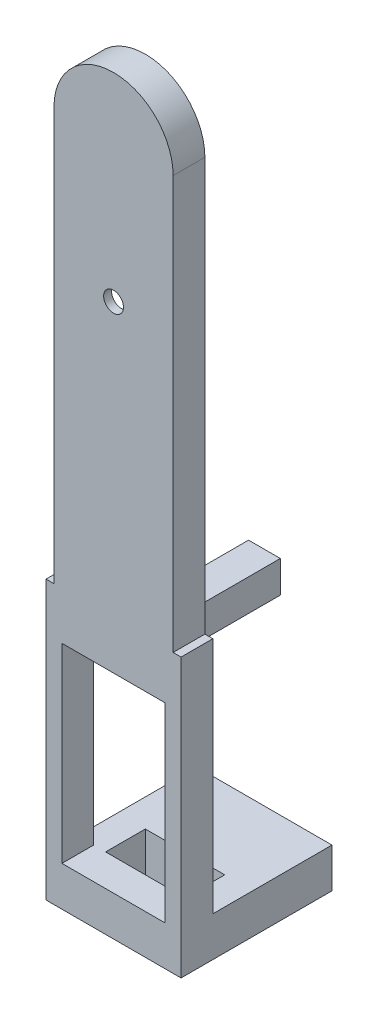
from build123d import *

# Parameters (mm, degrees)
EXTRUDE_1_DEPTH     = 4
CUT_EXTRUDE_1_DEPTH = 3
SKETCH_5_R          = 1.25
CUT_EXTRUDE_2_DEPTH = 12.4
SKETCH_6_W          = 17
SKETCH_6_H          = 35
EXTRUDE_2_DEPTH     = 4
SKETCH_7_W          = 13
SKETCH_7_H          = 24
CUT_EXTRUDE_3_DEPTH = 12.1
SKETCH_8_W          = 4
SKETCH_8_H          = 4
SKETCH_8_R          = 1.15
EXTRUDE_3_DEPTH     = 15
EXTRUDE_4_DEPTH     = 5
SKETCH_10_R         = 1.15
CUT_EXTRUDE_4_DEPTH = 12.7


with BuildPart() as part:
    # 草圖1 → 填料-伸長1 (new body)
    with BuildSketch(Plane.XY):
        with BuildLine():
            Line((7.5, 0), (7.5, 52))
            ThreePointArc((7.5, 52), (0, 59.5), (-7.5, 52))
            Line((-7.5, 52), (-7.5, 0))
            Line((-7.5, 0), (7.5, 0))
        make_face()
    extrude(amount=EXTRUDE_1_DEPTH)

    # 草圖3 → 除料-伸長1 (cut)
    with BuildSketch(Plane.XY):
        with BuildLine():
            ThreePointArc((-2.132795501, 52), (0, 54.132795501), (2.132795501, 52))
            Line((2.132795501, 52), (5, 34.5))
            Line((5, 34.5), (2.114741289, 16.658021353))
            ThreePointArc((2.114741289, 16.658021353), (-0.171540182, 14.864665347), (-2.142213835, 17))
            Line((-2.142213835, 17), (-5, 34.5))
            Line((-5, 34.5), (-2.132795501, 52))
        make_face()
    extrude(amount=CUT_EXTRUDE_1_DEPTH, mode=Mode.SUBTRACT)

    # 草圖5 → 除料-伸長2 (cut)
    with BuildSketch(Plane.XY):
        with Locations((0, 34.5)):
            Circle(SKETCH_5_R)
    extrude(amount=CUT_EXTRUDE_2_DEPTH, mode=Mode.SUBTRACT)

    # 草圖6 → 填料-伸長2 (add)
    with BuildSketch(Plane.XY):
        with Locations((0, -17.5)):
            Rectangle(SKETCH_6_W, SKETCH_6_H)
    extrude(amount=EXTRUDE_2_DEPTH)

    # 草圖7 → 除料-伸長3 (cut)
    with BuildSketch(Plane.XY):
        with Locations((0, -18)):
            Rectangle(SKETCH_7_W, SKETCH_7_H)
    extrude(amount=CUT_EXTRUDE_3_DEPTH, mode=Mode.SUBTRACT)

    # 草圖8 → 填料-伸長3 (add)
    with BuildSketch(Plane.XY):
        with Locations((0, -4)):
            Rectangle(SKETCH_8_W, SKETCH_8_H)
        with Locations((0, -4)):
            Circle(SKETCH_8_R, mode=Mode.SUBTRACT)
    extrude(amount=-EXTRUDE_3_DEPTH)

    # 草圖9 → 填料-伸長4 (add)
    with BuildSketch(Plane(origin=(0, -35, 0), x_dir=(1, 0, 0), z_dir=(0, 1, 0))):
        Polygon((-8.5, 0), (-5, 0), (-5, 5), (5, 5), (5, 0), (8.5, 0), (8.5, 15), (-8.5, 15), align=None)
    extrude(amount=EXTRUDE_4_DEPTH)

    # 草圖10 → 除料-伸長4 (cut)
    with BuildSketch(Plane(origin=(0, 0, -15), x_dir=(-1, 0, 0), z_dir=(0, 0, -1))):
        with Locations((0, -32.5)):
            Circle(SKETCH_10_R)
    extrude(amount=-CUT_EXTRUDE_4_DEPTH, mode=Mode.SUBTRACT)


solid = part.part
